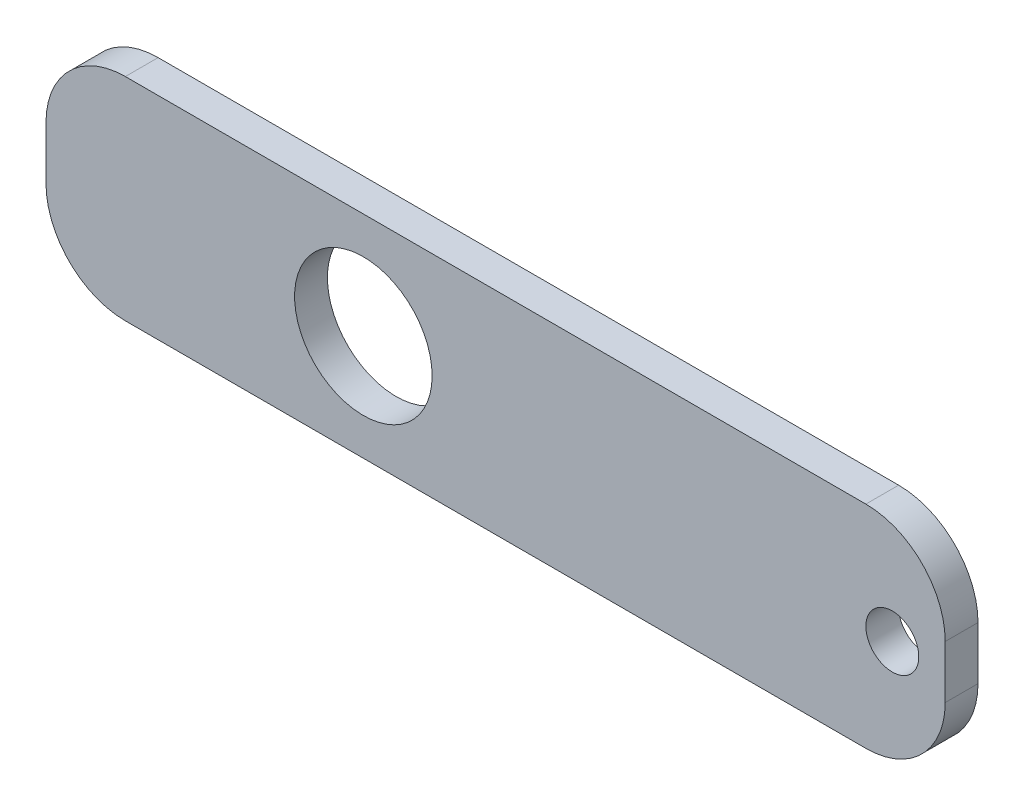
from build123d import *

# Parameters (mm, degrees)
SKETCH1_W           = 85
SKETCH1_H           = 20
SKETCH1_R           = 2.5
SKETCH1_R_2         = 6.5
BOSS_EXTRUDE1_DEPTH = 3.1
FILLET1_R           = 7.5


with BuildPart() as part:
    # Sketch1 → Boss-Extrude1 (new body)
    with BuildSketch(Plane.XY):
        with Locations((-5.11937671, 0)):
            Rectangle(SKETCH1_W, SKETCH1_H)
        with Locations((32.38062329, 0)):
            Circle(SKETCH1_R, mode=Mode.SUBTRACT)
        with Locations((-17.61937671, 0)):
            Circle(SKETCH1_R_2, mode=Mode.SUBTRACT)
    extrude(amount=BOSS_EXTRUDE1_DEPTH)

    # Fillet1
    fillet1_edges = [part.edges().sort_by_distance(p)[0] for p in [
        (-47.61937671, 10, 1.55),
        (37.38062329, 10, 1.55),
        (37.38062329, -10, 1.55),
        (-47.61937671, -10, 1.55),
    ]]
    fillet(fillet1_edges, radius=FILLET1_R)


solid = part.part
